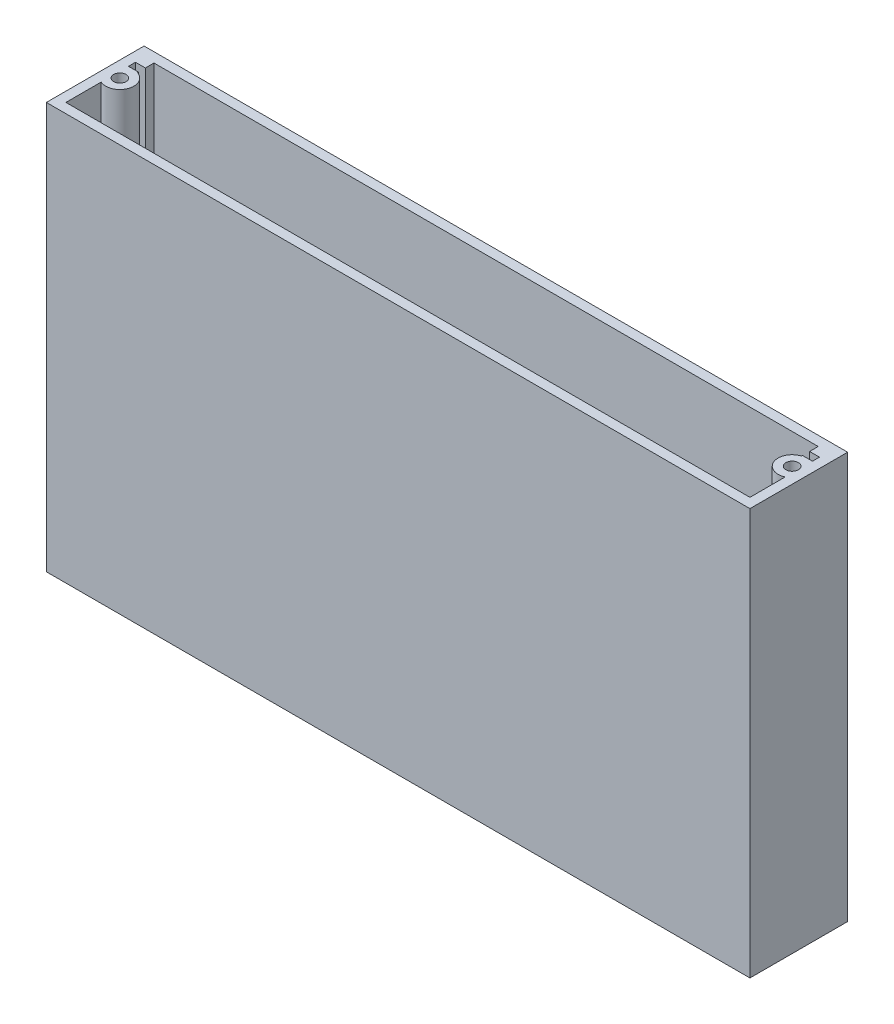
from build123d import *

# Parameters (mm, degrees)
SKETCH1_W           = 228.6
SKETCH1_H           = 31.75
BOSS_EXTRUDE1_DEPTH = 132.08
SKETCH2_W           = 222.25
SKETCH2_H           = 25.4
CUT_EXTRUDE1_DEPTH  = 128.905
SKETCH3_W           = 3.216999687
SKETCH3_H           = 4.15103562
SKETCH3_H_2         = 5.08
BOSS_EXTRUDE2_DEPTH = 128.905
SKETCH4_R           = 4.572
BOSS_EXTRUDE3_DEPTH = 128.905
SKETCH5_R           = 2.032
CUT_EXTRUDE2_DEPTH  = 123.825


with BuildPart() as part:
    # Sketch1 → Boss-Extrude1 (new body)
    with BuildSketch(Plane(origin=(0, 0, 0), x_dir=(1, 0, 0), z_dir=(0, 1, 0))):
        with Locations((114.3, 15.875)):
            Rectangle(SKETCH1_W, SKETCH1_H)
    extrude(amount=BOSS_EXTRUDE1_DEPTH)

    # Sketch2 → Cut-Extrude1 (cut)
    with BuildSketch(Plane(origin=(0, 132.08, 0), x_dir=(1, 0, 0), z_dir=(0, 1, 0))):
        with Locations((114.3, 15.875)):
            Rectangle(SKETCH2_W, SKETCH2_H)
    extrude(amount=-CUT_EXTRUDE1_DEPTH, mode=Mode.SUBTRACT)

    # Sketch3 → Boss-Extrude2 (add)
    with BuildSketch(Plane(origin=(0, 3.175, 0), x_dir=(1, 0, 0), z_dir=(0, 1, 0))):
        with Locations((4.783499844, 27.85651781)):
            Rectangle(SKETCH3_W, SKETCH3_H)
        with Locations((4.783499844, 20.955)):
            Rectangle(SKETCH3_W, SKETCH3_H_2)
    boss_extrude2 = extrude(amount=BOSS_EXTRUDE2_DEPTH)

    # Mirror1: Boss-Extrude2 across plane
    add(boss_extrude2.mirror(Plane.ZY.offset(-114.3)))

    # Sketch4 → Boss-Extrude3 (add)
    with BuildSketch(Plane(origin=(0, 3.175, 0), x_dir=(1, 0, 0), z_dir=(0, 1, 0))):
        with Locations((5.08, 18.796)):
            Circle(SKETCH4_R)
        with Locations((223.52, 18.796)):
            Circle(SKETCH4_R)
    extrude(amount=BOSS_EXTRUDE3_DEPTH)

    # Sketch5 → Cut-Extrude2 (cut)
    with BuildSketch(Plane(origin=(0, 132.08, 0), x_dir=(1, 0, 0), z_dir=(0, 1, 0))):
        with Locations((5.08, 18.796)):
            Circle(SKETCH5_R)
        with Locations((223.52, 18.796)):
            Circle(SKETCH5_R)
    extrude(amount=-CUT_EXTRUDE2_DEPTH, mode=Mode.SUBTRACT)


solid = part.part
